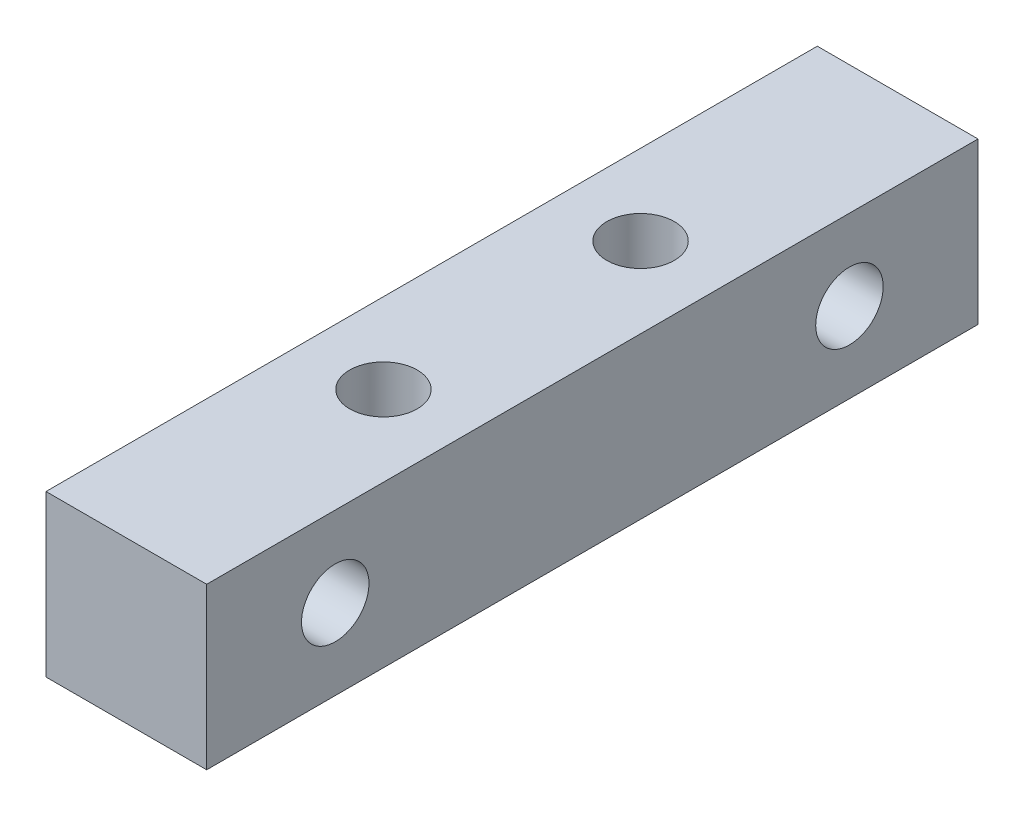
from build123d import *

# Parameters (mm, degrees)
SKETCH_1_W          = 10
SKETCH_1_H          = 10
EXTRUDE_1_DEPTH     = 48
SKETCH_2_R          = 2.1
CUT_EXTRUDE_1_DEPTH = 48
SKETCH_3_R          = 2.1
CUT_EXTRUDE_2_DEPTH = 48


with BuildPart() as part:
    # 草图1 → 凸台-拉伸1 (new body)
    with BuildSketch(Plane.XY):
        with Locations((5, -5)):
            Rectangle(SKETCH_1_W, SKETCH_1_H)
    extrude(amount=EXTRUDE_1_DEPTH)

    # 草图2 → 切除-拉伸1 (cut)
    with BuildSketch(Plane(origin=(10, 0, 0), x_dir=(0, 0, -1), z_dir=(1, 0, 0))):
        with Locations((-40, -5)):
            Circle(SKETCH_2_R)
        with Locations((-8, -5)):
            Circle(SKETCH_2_R)
    extrude(amount=-CUT_EXTRUDE_1_DEPTH, mode=Mode.SUBTRACT)

    # 草图3 → 切除-拉伸2 (cut)
    with BuildSketch(Plane(origin=(0, 0, 0), x_dir=(1, 0, 0), z_dir=(0, 1, 0))):
        with Locations((5, -16)):
            Circle(SKETCH_3_R)
        with Locations((5, -32)):
            Circle(SKETCH_3_R)
    extrude(amount=-CUT_EXTRUDE_2_DEPTH, mode=Mode.SUBTRACT)


solid = part.part
